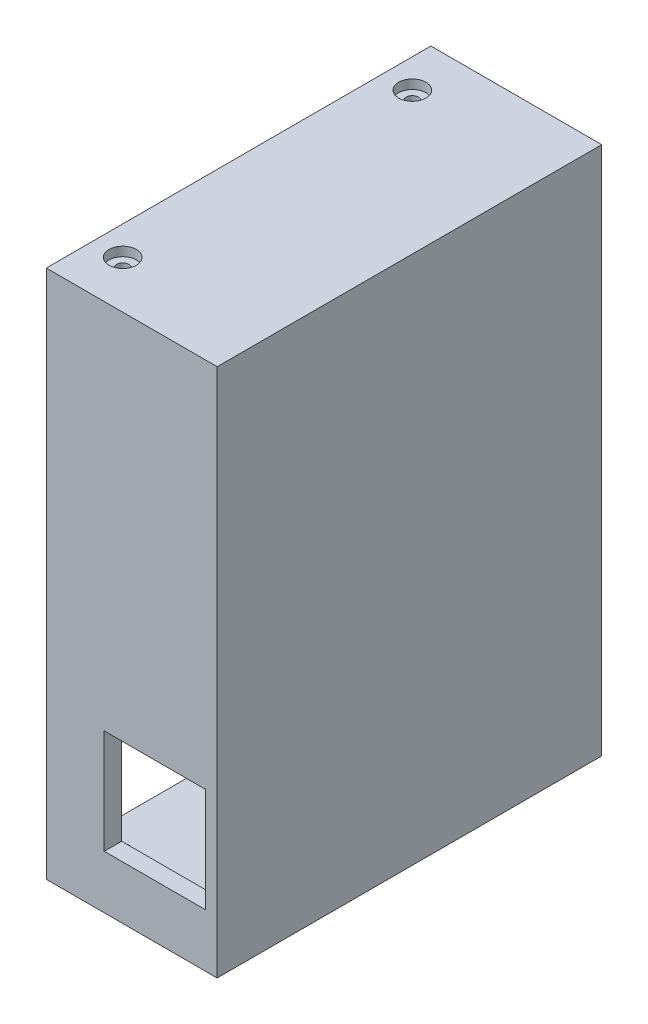
from build123d import *

# Parameters (mm, degrees)
SKETCH1_W           = 116.070000016
SKETCH1_H           = 84.320000016
BOSS_EXTRUDE1_DEPTH = 2.54
SKETCH2_W           = 116.070000016
SKETCH2_H           = 84.320000016
SKETCH2_W_2         = 108.450000016
SKETCH2_H_2         = 76.700000016
BOSS_EXTRUDE2_DEPTH = 34.925
CUT_EXTRUDE1_START  = 0.25
SKETCH4_R           = 1.349999967
CUT_EXTRUDE1_DEPTH  = 3.81
CUT_EXTRUDE2_START  = 0.25
SKETCH5_R           = 1.349999967
CUT_EXTRUDE2_DEPTH  = 3.81
SKETCH7_R           = 2.999999969
CUT_EXTRUDE3_DEPTH  = 2.000000064
SKETCH6_R           = 2.999999969
CUT_EXTRUDE4_DEPTH  = 2.000000064
CUT_EXTRUDE5_START  = 0.25
SKETCH11_W          = 22.225
SKETCH11_H          = 22.86
CUT_EXTRUDE5_DEPTH  = 3.81
CUT_EXTRUDE6_START  = 0.25
SKETCH8_W           = 22.225
SKETCH8_H           = 25.4
CUT_EXTRUDE6_DEPTH  = 3.81
CUT_EXTRUDE7_START  = 0.25
SKETCH10_W          = 22.225
SKETCH10_H          = 22.86
CUT_EXTRUDE7_DEPTH  = 3.81


with BuildPart() as part:
    # Sketch1 → Boss-Extrude1 (new body)
    with BuildSketch(Plane.YZ):
        Rectangle(SKETCH1_W, SKETCH1_H)
    extrude(amount=BOSS_EXTRUDE1_DEPTH)

    # Sketch2 → Boss-Extrude2 (add)
    with BuildSketch(Plane(origin=(0, 0, 0), x_dir=(0, -1, 0), z_dir=(-1, 0, 0))):
        Rectangle(SKETCH2_W, SKETCH2_H)
        Rectangle(SKETCH2_W_2, SKETCH2_H_2, mode=Mode.SUBTRACT)
    extrude(amount=BOSS_EXTRUDE2_DEPTH)

    # Sketch4 → Cut-Extrude1 (cut)
    with BuildSketch(Plane.XZ.offset(53.975).offset(CUT_EXTRUDE1_START)):
        with Locations((-28.575, 31.75)):
            Circle(SKETCH4_R)
        with Locations((-28.575, -31.75)):
            Circle(SKETCH4_R)
    extrude(amount=CUT_EXTRUDE1_DEPTH, mode=Mode.SUBTRACT)

    # Sketch5 → Cut-Extrude2 (cut)
    with BuildSketch(Plane(origin=(0, 53.975, 0), x_dir=(-1, 0, 0), z_dir=(0, 1, 0)).offset(CUT_EXTRUDE2_START)):
        with Locations((28.575, -31.75)):
            Circle(SKETCH5_R)
        with Locations((28.575, 31.75)):
            Circle(SKETCH5_R)
    extrude(amount=CUT_EXTRUDE2_DEPTH, mode=Mode.SUBTRACT)

    # Sketch7 → Cut-Extrude3 (cut)
    with BuildSketch(Plane(origin=(0, 58.035000008, 0), x_dir=(-1, 0, 0), z_dir=(0, 1, 0))):
        with Locations((28.575, -31.75)):
            Circle(SKETCH7_R)
        with Locations((28.575, 31.75)):
            Circle(SKETCH7_R)
    extrude(amount=-CUT_EXTRUDE3_DEPTH, mode=Mode.SUBTRACT)

    # Sketch6 → Cut-Extrude4 (cut)
    with BuildSketch(Plane.XZ.offset(58.035000008)):
        with Locations((-28.575, 31.75)):
            Circle(SKETCH6_R)
        with Locations((-28.575, -31.75)):
            Circle(SKETCH6_R)
    extrude(amount=-CUT_EXTRUDE4_DEPTH, mode=Mode.SUBTRACT)

    # Sketch11 → Cut-Extrude5 (cut)
    with BuildSketch(Plane(origin=(0, 0, -38.1), x_dir=(1, 0, 0), z_dir=(0, 0, -1)).offset(CUT_EXTRUDE5_START)):
        with Locations((-11.1125, 34.925)):
            Rectangle(SKETCH11_W, SKETCH11_H)
    extrude(amount=CUT_EXTRUDE5_DEPTH, mode=Mode.SUBTRACT)

    # Sketch8 → Cut-Extrude6 (cut)
    with BuildSketch(Plane.XZ.offset(53.975).offset(CUT_EXTRUDE6_START)):
        with Locations((-11.1125, -12.7)):
            Rectangle(SKETCH8_W, SKETCH8_H)
    extrude(amount=CUT_EXTRUDE6_DEPTH, mode=Mode.SUBTRACT)

    # Sketch10 → Cut-Extrude7 (cut)
    with BuildSketch(Plane.XY.offset(38.1).offset(CUT_EXTRUDE7_START)):
        with Locations((-11.1125, -34.925)):
            Rectangle(SKETCH10_W, SKETCH10_H)
    extrude(amount=CUT_EXTRUDE7_DEPTH, mode=Mode.SUBTRACT)


solid = part.part
